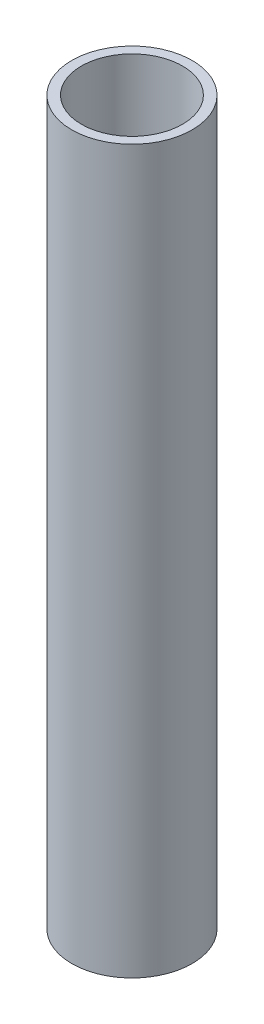
from build123d import *

# Parameters (mm, degrees)
SKETCH1_R               = 3.175
BOSS_EXTRUDE1_DEPTH     = 19.05
SKETCH2_R               = 2.667
CUT_EXTRUDE1_DEPTH      = 20.05
CUT_EXTRUDE1_DEPTH_BACK = 20.05


with BuildPart() as part:
    # Sketch1 → Boss-Extrude1 (new body, symmetric)
    with BuildSketch(Plane(origin=(0, 0, 0), x_dir=(1, 0, 0), z_dir=(0, 1, 0))):
        Circle(SKETCH1_R)
    extrude(amount=BOSS_EXTRUDE1_DEPTH, both=True)

    # Sketch2 → Cut-Extrude1 (cut, two sides)
    with BuildSketch(Plane(origin=(0, 0, 0), x_dir=(1, 0, 0), z_dir=(0, 1, 0))) as cut_extrude1_sk:
        Circle(SKETCH2_R)
    extrude(amount=CUT_EXTRUDE1_DEPTH, mode=Mode.SUBTRACT)
    extrude(cut_extrude1_sk.sketch, amount=-CUT_EXTRUDE1_DEPTH_BACK, mode=Mode.SUBTRACT)


solid = part.part
